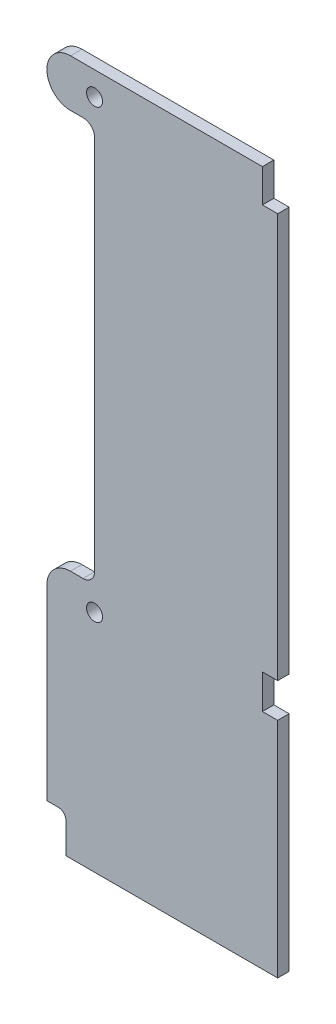
from build123d import *

# Parameters (mm, degrees)
SKETCH1_R           = 2.1
BOSS_EXTRUDE1_DEPTH = 3


with BuildPart() as part:
    # Sketch1 → Boss-Extrude1 (new body)
    with BuildSketch(Plane.XY):
        with BuildLine():
            Line((-6.3, 110.8), (-3, 110.8))
            ThreePointArc((-3, 110.8), (-0.878679656, 109.921320344), (0, 107.8))
            Line((0, 107.8), (0, 9.2))
            ThreePointArc((0, 9.2), (-0.878679656, 7.078679656), (-3, 6.2))
            Line((-3, 6.2), (-6.3, 6.2))
            ThreePointArc((-6.3, 6.2), (-10.684062043, 4.384062043), (-12.5, 0))
            Line((-12.5, 0), (-12.5, -49))
            Line((-12.5, -49), (-9.5, -49))
            ThreePointArc((-9.5, -49), (-8.085786438, -49.585786438), (-7.5, -51))
            Line((-7.5, -51), (-7.5, -59))
            Line((-7.5, -59), (48, -59))
            Line((48, -59), (48, -0.5))
            Line((48, -0.5), (44, -0.5))
            Line((44, -0.5), (44, 8.5))
            Line((44, 8.5), (48, 8.5))
            Line((48, 8.5), (48, 114.5))
            Line((48, 114.5), (44, 114.5))
            Line((44, 114.5), (44, 123.2))
            Line((44, 123.2), (-6.3, 123.2))
            ThreePointArc((-6.3, 123.2), (-12.5, 117), (-6.3, 110.8))
        make_face()
        Circle(SKETCH1_R, mode=Mode.SUBTRACT)
        with Locations((0, 117)):
            Circle(SKETCH1_R, mode=Mode.SUBTRACT)
    extrude(amount=BOSS_EXTRUDE1_DEPTH)


solid = part.part
